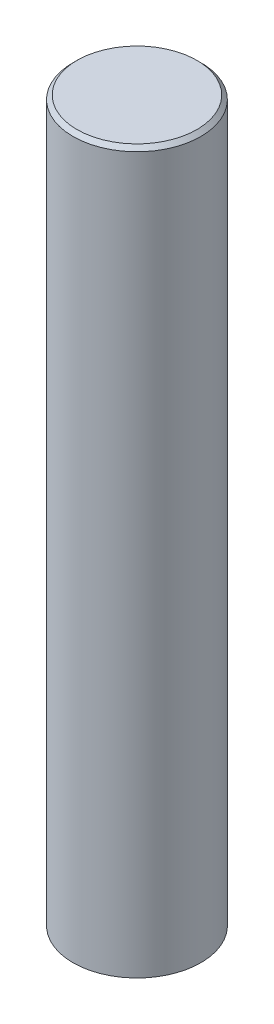
from build123d import *

# Parameters (mm, degrees)
SKETCH1_R           = 16
BOSS_EXTRUDE1_DEPTH = 180
CHAMFER1_SIZE       = 1


with BuildPart() as part:
    # Sketch1 → Boss-Extrude1 (new body)
    with BuildSketch(Plane(origin=(0, 0, 0), x_dir=(1, 0, 0), z_dir=(0, 1, 0))):
        Circle(SKETCH1_R)
    extrude(amount=BOSS_EXTRUDE1_DEPTH)

    # Chamfer1
    chamfer1_edges = [part.edges().sort_by_distance(p)[0] for p in [
        (-16, 180, 0),
    ]]
    chamfer(chamfer1_edges, length=CHAMFER1_SIZE)


solid = part.part
